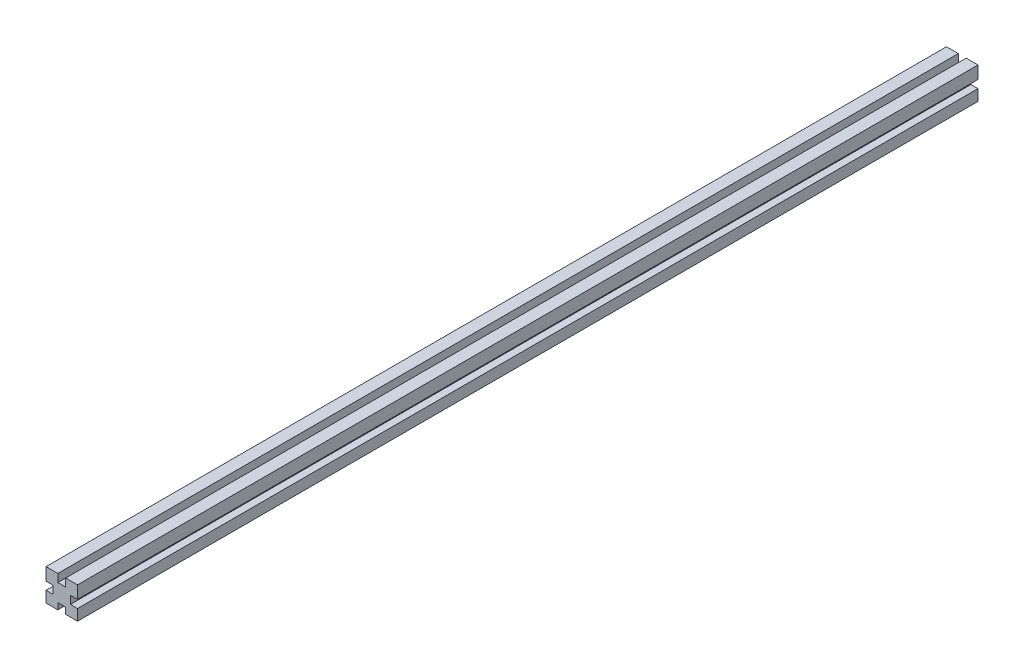
from build123d import *

# Parameters (mm, degrees)
SKETCH1_W           = 20
SKETCH1_H           = 20
BOSS_EXTRUDE1_DEPTH = 571
SKETCH2_W           = 5
SKETCH2_H           = 10
CUT_EXTRUDE1_DEPTH  = 572
CIRPATTERN1_COUNT   = 4


with BuildPart() as part:
    # Sketch1 → Boss-Extrude1 (new body)
    with BuildSketch(Plane.XY):
        Rectangle(SKETCH1_W, SKETCH1_H)
    extrude(amount=-BOSS_EXTRUDE1_DEPTH)

    # Sketch2 → Cut-Extrude1 (cut, through all)
    with BuildSketch(Plane.XY):
        with Locations((0, 10)):
            Rectangle(SKETCH2_W, SKETCH2_H)
    cut_extrude1 = extrude(amount=-CUT_EXTRUDE1_DEPTH, mode=Mode.SUBTRACT)

    # CirPattern1: Cut-Extrude1 ×4 about axis
    cirpattern1_axis = Axis((0, -0.5, 0), (0, 0, 1))
    for i in range(1, CIRPATTERN1_COUNT):
        add(cut_extrude1.rotate(cirpattern1_axis, i * 360 / CIRPATTERN1_COUNT), mode=Mode.SUBTRACT)


solid = part.part
